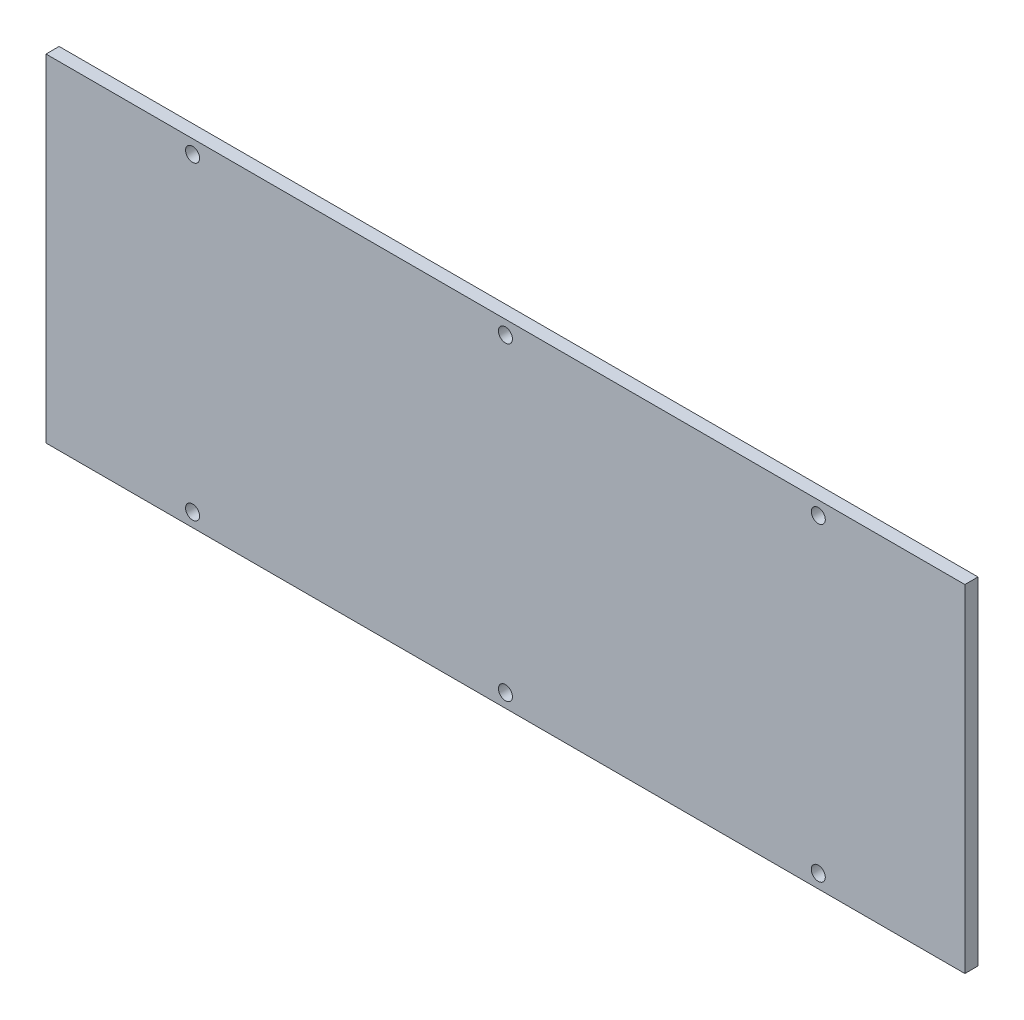
from build123d import *

# Parameters (mm, degrees)
CROQUIS1_W              = 210
CROQUIS1_H              = 77
CROQUIS1_R              = 1.6
SALIENTE_EXTRUIR1_DEPTH = 3


with BuildPart() as part:
    # Croquis1 → Saliente-Extruir1 (new body)
    with BuildSketch(Plane.XY):
        Rectangle(CROQUIS1_W, CROQUIS1_H)
        with Locations((0, 35.4)):
            Circle(CROQUIS1_R, mode=Mode.SUBTRACT)
        with Locations((-71.5, 35.4)):
            Circle(CROQUIS1_R, mode=Mode.SUBTRACT)
        with Locations((71.5, 35.4)):
            Circle(CROQUIS1_R, mode=Mode.SUBTRACT)
        with Locations((71.5, -35.4)):
            Circle(CROQUIS1_R, mode=Mode.SUBTRACT)
        with Locations((0, -35.4)):
            Circle(CROQUIS1_R, mode=Mode.SUBTRACT)
        with Locations((-71.5, -35.4)):
            Circle(CROQUIS1_R, mode=Mode.SUBTRACT)
    extrude(amount=SALIENTE_EXTRUIR1_DEPTH)


solid = part.part
